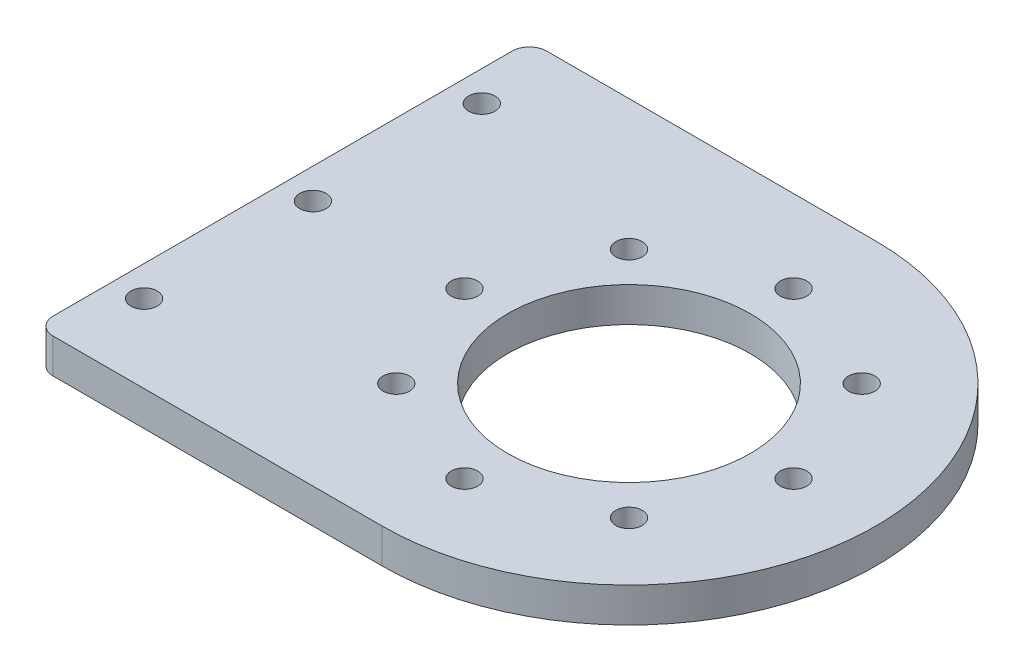
from build123d import *

# Parameters (mm, degrees)
EXTRUDE_1_DEPTH     = 4
SKETCH_3_R          = 1.525
CUT_EXTRUDE_1_DEPTH = 5
SKETCH_4_R          = 14
CUT_EXTRUDE_2_DEPTH = 5
SKETCH_7_R          = 1.525
CUT_EXTRUDE_4_DEPTH = 5
SKETCH_8_W          = 1
SKETCH_8_H          = 57
EXTRUDE_2_DEPTH     = 4
FILLET_1_R          = 2


with BuildPart() as part:
    # 草图1 → 凸台-拉伸1 (new body)
    with BuildSketch(Plane(origin=(0, 0, 0), x_dir=(1, 0, 0), z_dir=(0, 1, 0))):
        with BuildLine():
            ThreePointArc((19.5, 28.5), (-9, 0), (19.5, -28.5))
            Line((19.5, -28.5), (19.5, 28.5))
        make_face()
        with BuildLine():
            Line((19.5, 28.5), (19.5, -28.5))
            ThreePointArc((19.5, -28.5), (39.652543264, -20.152543264), (48, 0))
            ThreePointArc((48, 0), (39.652543264, 20.152543264), (19.5, 28.5))
        make_face()
        with BuildLine():
            Line((-19.5, 28.5), (-19.5, -28.5))
            Line((-19.5, -28.5), (19.5, -28.5))
            ThreePointArc((19.5, -28.5), (-9, 0), (19.5, 28.5))
            Line((19.5, 28.5), (-19.5, 28.5))
        make_face()
    extrude(amount=EXTRUDE_1_DEPTH)

    # 草图3 → 切除-拉伸1 (cut, through all)
    with BuildSketch(Plane(origin=(0, 4, 0), x_dir=(1, 0, 0), z_dir=(0, 1, 0))):
        with Locations((32.935028843, 13.435028843)):
            Circle(SKETCH_3_R)
        with Locations((32.935028843, -13.435028843)):
            Circle(SKETCH_3_R)
        with Locations((6.064971157, -13.435028843)):
            Circle(SKETCH_3_R)
        with Locations((6.064971157, 13.435028843)):
            Circle(SKETCH_3_R)
        with Locations((38.5, 0)):
            Circle(SKETCH_3_R)
        with Locations((19.5, -19)):
            Circle(SKETCH_3_R)
        with Locations((0.5, 0)):
            Circle(SKETCH_3_R)
        with Locations((19.5, 19)):
            Circle(SKETCH_3_R)
    extrude(amount=-CUT_EXTRUDE_1_DEPTH, mode=Mode.SUBTRACT)

    # 草图4 → 切除-拉伸2 (cut, through all)
    with BuildSketch(Plane(origin=(0, 4, 0), x_dir=(1, 0, 0), z_dir=(0, 1, 0))):
        with Locations((19.5, 0)):
            Circle(SKETCH_4_R)
    extrude(amount=-CUT_EXTRUDE_2_DEPTH, mode=Mode.SUBTRACT)

    # 草图7 → 切除-拉伸4 (cut, through all)
    with BuildSketch(Plane.XZ):
        with Locations((-17, 0)):
            Circle(SKETCH_7_R)
        with Locations((-17, 19.5)):
            Circle(SKETCH_7_R)
        with Locations((-17, -19.5)):
            Circle(SKETCH_7_R)
    extrude(amount=-CUT_EXTRUDE_4_DEPTH, mode=Mode.SUBTRACT)

    # 草图8 → 凸台-拉伸2 (add)
    with BuildSketch(Plane(origin=(0, 4, 0), x_dir=(1, 0, 0), z_dir=(0, 1, 0))):
        with Locations((-20, 0)):
            Rectangle(SKETCH_8_W, SKETCH_8_H)
    extrude(amount=-EXTRUDE_2_DEPTH)

    # 圆角1
    fillet_1_edges = [part.edges().sort_by_distance(p)[0] for p in [
        (-20.5, 2, 28.5),
        (-20.5, 2, -28.5),
    ]]
    fillet(fillet_1_edges, radius=FILLET_1_R)


solid = part.part
